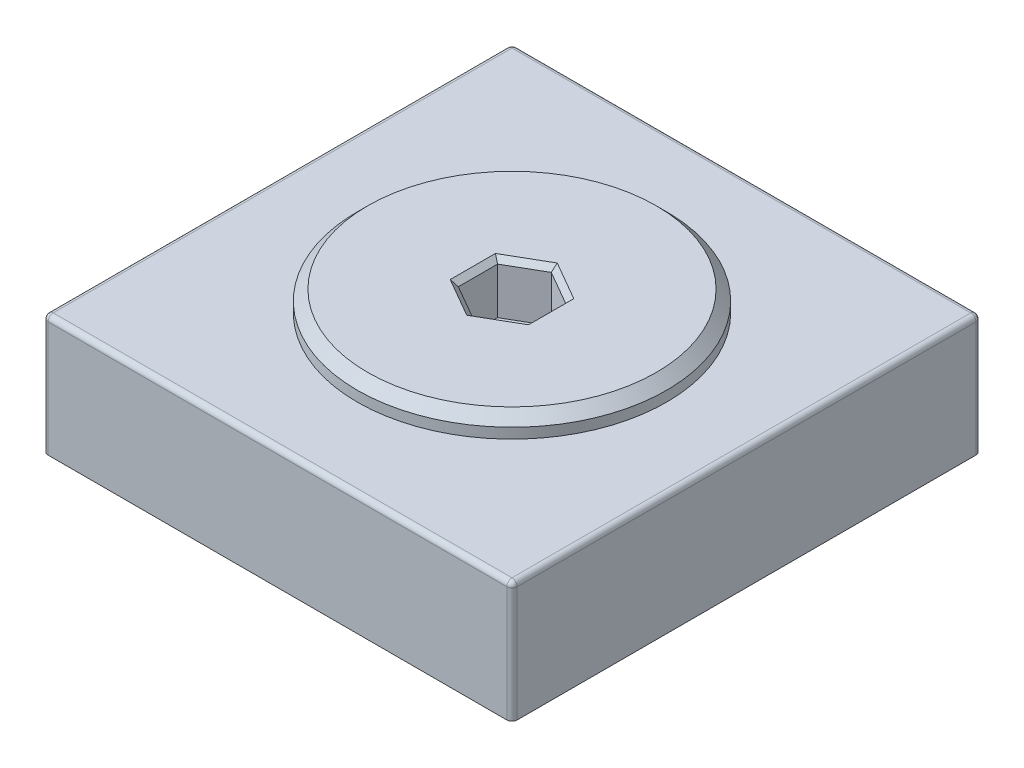
from build123d import *

# Parameters (mm, degrees)
SKETCH1_W           = 45.5
SKETCH1_H           = 45.5
BOSS_EXTRUDE1_DEPTH = 11.7
SKETCH2_R           = 15
BOSS_EXTRUDE2_DEPTH = 2
CHAMFER1_SIZE       = 1
CUT_EXTRUDE1_DEPTH  = 5
CHAMFER2_SIZE       = 0.5
FILLET1_R           = 0.5
SKETCH4_R           = 15
BOSS_EXTRUDE3_DEPTH = 5


with BuildPart() as part:
    # Sketch1 → Boss-Extrude1 (new body)
    with BuildSketch(Plane(origin=(0, 0, 0), x_dir=(1, 0, 0), z_dir=(0, 1, 0))):
        Rectangle(SKETCH1_W, SKETCH1_H)
    extrude(amount=BOSS_EXTRUDE1_DEPTH)

    # Sketch2 → Boss-Extrude2 (add)
    with BuildSketch(Plane(origin=(0, 11.7, 0), x_dir=(1, 0, 0), z_dir=(0, 1, 0))):
        Circle(SKETCH2_R)
    extrude(amount=BOSS_EXTRUDE2_DEPTH)

    # Chamfer1
    chamfer1_edges = [part.edges().sort_by_distance(p)[0] for p in [
        (-15, 13.7, 0),
    ]]
    chamfer(chamfer1_edges, length=CHAMFER1_SIZE)

    # Sketch3 → Cut-Extrude1 (cut)
    with BuildSketch(Plane(origin=(0, 13.7, 0), x_dir=(1, 0, 0), z_dir=(0, 1, 0))):
        Polygon((0, 3.810511777), (-3.3, 1.905255888), (-3.3, -1.905255888), (0, -3.810511777), (3.3, -1.905255888), (3.3, 1.905255888), align=None)
    extrude(amount=-CUT_EXTRUDE1_DEPTH, mode=Mode.SUBTRACT)

    # Chamfer2
    chamfer2_edges = [part.edges().sort_by_distance(p)[0] for p in [
        (1.65, 13.7, -2.857883832),
        (-1.65, 13.7, -2.857883832),
        (-3.3, 13.7, 0),
        (-1.65, 13.7, 2.857883832),
        (1.65, 13.7, 2.857883832),
        (3.3, 13.7, 0),
    ]]
    chamfer(chamfer2_edges, length=CHAMFER2_SIZE)

    # Fillet1
    fillet1_edges = [part.edges().sort_by_distance(p)[0] for p in [
        (-22.75, 11.7, 0),
        (0, 11.7, 22.75),
        (22.75, 11.7, 0),
        (22.75, 5.85, 22.75),
        (-22.75, 5.85, 22.75),
        (-22.75, 5.85, -22.75),
        (22.75, 5.85, -22.75),
        (0, 11.7, -22.75),
    ]]
    fillet(fillet1_edges, radius=FILLET1_R)

    # Sketch4 → Boss-Extrude3 (add)
    with BuildSketch(Plane(origin=(0, 0, 0), x_dir=(-1, 0, 0), z_dir=(0, -1, 0))):
        Circle(SKETCH4_R)
    extrude(amount=BOSS_EXTRUDE3_DEPTH)


solid = part.part
